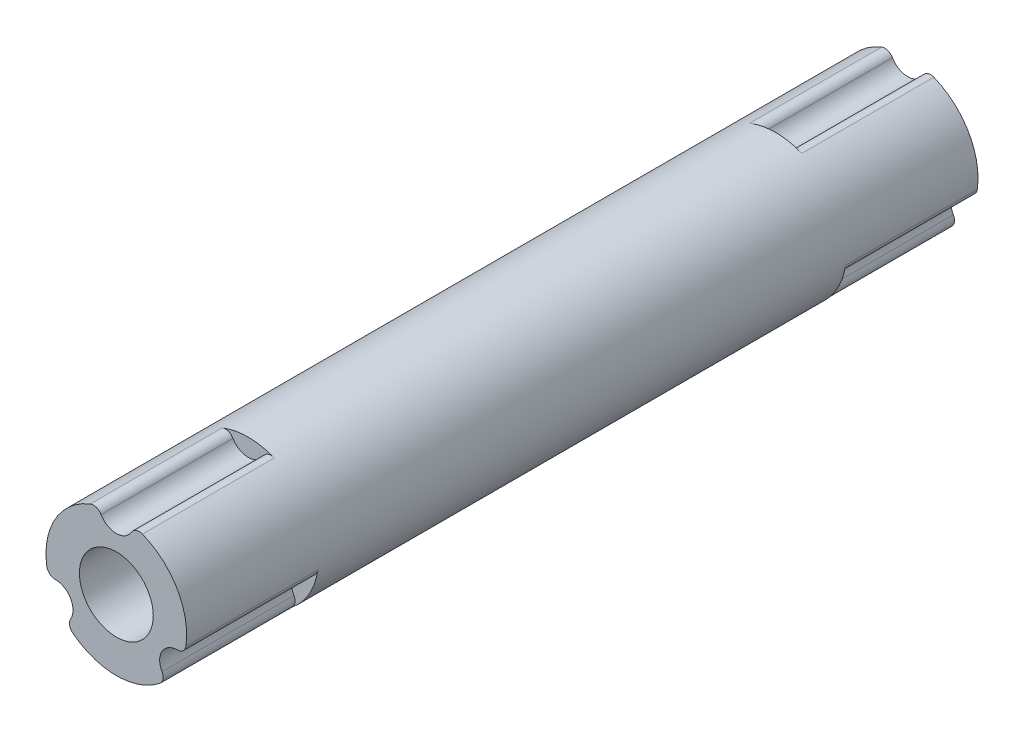
from build123d import *

# Parameters (mm, degrees)
BOSS_EXTRU_1_DEPTH           = 22.5
R_P_TITION_CIRCULAIRE2_COUNT = 3
TROU_TARAUD_M51_D            = 4.2
TROU_TARAUD_M51_DEPTH        = 14
TROU_TARAUD_M51_TIP          = 1.2618073
TROU_TARAUD_M52_D            = 4.2
TROU_TARAUD_M52_DEPTH        = 14
TROU_TARAUD_M52_TIP          = 1.2618073
ESQUISSE6_R                  = 4
ESQUISSE6_R_2                = 2.807618462
BOSS_EXTRU_2_DEPTH           = 15


with BuildPart() as part:
    # Esquisse1 → Boss.-Extru.1 (new body, symmetric)
    with BuildSketch(Plane.XY):
        with BuildLine():
            Line((0, 0), (-3.464101615, 2))
            ThreePointArc((-3.464101615, 2), (-2.618614683, 3.023715784), (-1.484614978, 3.714285714))
            ThreePointArc((-1.484614978, 3.714285714), (-1.135374688, 3.722455591), (-0.866025404, 3.5))
            ThreePointArc((-0.866025404, 3.5), (0, 3), (0.866025404, 3.5))
            ThreePointArc((0.866025404, 3.5), (1.135374688, 3.722455591), (1.484614978, 3.714285714))
            ThreePointArc((1.484614978, 3.714285714), (2.618614683, 3.023715784), (3.464101615, 2))
            Line((3.464101615, 2), (0, 0))
        make_face()
    boss_extru_1 = extrude(amount=BOSS_EXTRU_1_DEPTH, both=True)

    # R_p_tition circulaire2: Boss.-Extru.1 ×3 about axis
    r_p_tition_circulaire2_axis = Axis((0, 0, 0), (0, 0, 1))
    for i in range(1, R_P_TITION_CIRCULAIRE2_COUNT):
        add(boss_extru_1.rotate(r_p_tition_circulaire2_axis, i * 360 / R_P_TITION_CIRCULAIRE2_COUNT))

    # Trou taraud_ M51
    with Locations(Plane(origin=(0, 0, -22.5), x_dir=(-1, 0, 0), z_dir=(0, 0, -1))):
        with Locations((0, 0)):
            Hole(TROU_TARAUD_M51_D / 2, depth=TROU_TARAUD_M51_DEPTH)
            with Locations((0, 0, -(TROU_TARAUD_M51_DEPTH + TROU_TARAUD_M51_TIP / 2))):  # 118° drill point
                Cone(0, TROU_TARAUD_M51_D / 2, TROU_TARAUD_M51_TIP, mode=Mode.SUBTRACT)

    # Trou taraud_ M52
    with Locations(Plane.XY.offset(22.5)):
        with Locations((0, 0)):
            Hole(TROU_TARAUD_M52_D / 2, depth=TROU_TARAUD_M52_DEPTH)
            with Locations((0, 0, -(TROU_TARAUD_M52_DEPTH + TROU_TARAUD_M52_TIP / 2))):  # 118° drill point
                Cone(0, TROU_TARAUD_M52_D / 2, TROU_TARAUD_M52_TIP, mode=Mode.SUBTRACT)

    # Esquisse6 → Boss.-Extru.2 (add, symmetric)
    with BuildSketch(Plane.XY):
        with Locations(Location((0, 0, 0), (0, 0, 351.786789298))):  # turned: the seam where the file's is
            Circle(ESQUISSE6_R)
        Circle(ESQUISSE6_R_2, mode=Mode.SUBTRACT)
    extrude(amount=BOSS_EXTRU_2_DEPTH, both=True)


solid = part.part
